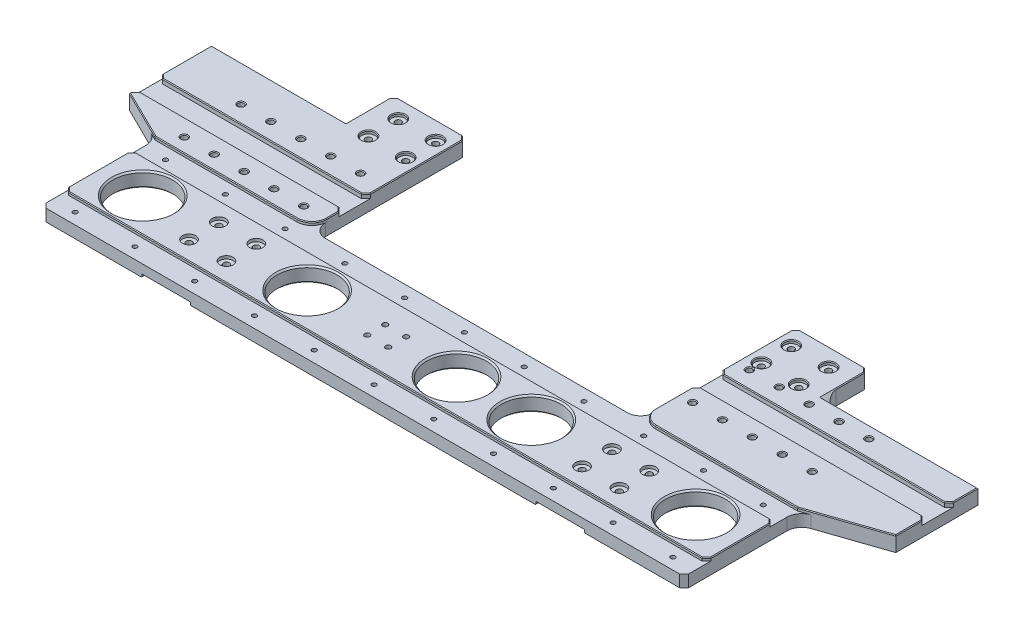
from build123d import *

# Parameters (mm, degrees)
SKETCH1_R           = 2
SKETCH1_R_2         = 20
BOSS_EXTRUDE1_DEPTH = 3
SKETCH2_W           = 11.375
SKETCH2_H           = 179.75
BOSS_EXTRUDE2_DEPTH = 2
SKETCH6_W           = 56
SKETCH6_H           = 76
BOSS_EXTRUDE5_DEPTH = 8
SKETCH3_W           = 430
SKETCH3_H           = 45.5
SKETCH3_R           = 20
SKETCH3_R_2         = 4.45
SKETCH3_W_2         = 49
SKETCH3_H_2         = 103.75
SKETCH3_R_3         = 2
BOSS_EXTRUDE3_DEPTH = 2
SKETCH4_R           = 2
SKETCH4_R_2         = 20
SKETCH4_W           = 10.75
SKETCH4_H           = 179.75
BOSS_EXTRUDE4_DEPTH = 2
FILLET1_R           = 10
FILLET2_R           = 9
SKETCH9_R           = 1.5
CUT_EXTRUDE2_DEPTH  = 9
BOSS_EXTRUDE6_DEPTH = 10
SKETCH11_R          = 2
CUT_EXTRUDE3_DEPTH  = 11
SKETCH13_R          = 20
CUT_EXTRUDE5_DEPTH  = 11
CHAMFER2_SIZE       = 1
SKETCH12_W          = 139
SKETCH12_H          = 15
SKETCH12_W_2        = 154
CUT_EXTRUDE4_DEPTH  = 3
CHAMFER1_SIZE       = 3
CHAMFER3_SIZE       = 0.5
FILLET3_R           = 10
SKETCH14_R          = 1.75
CUT_EXTRUDE6_DEPTH  = 11


with BuildPart() as part:
    # Sketch1 → Boss-Extrude1 (new body, symmetric)
    with BuildSketch(Plane(origin=(0, 0, 0), x_dir=(1, 0, 0), z_dir=(0, 1, 0))):
        Polygon((-110, 76), (110, 76), (110, 179.75), (159, 179.75), (159, 0), (-159, 0), (-159, 179.75), (-110, 179.75), align=None)
        with Locations((-119, 167.75)):
            Circle(SKETCH1_R, mode=Mode.SUBTRACT)
        with Locations((-144, 167.75)):
            Circle(SKETCH1_R, mode=Mode.SUBTRACT)
        with Locations((-144, 147.75)):
            Circle(SKETCH1_R, mode=Mode.SUBTRACT)
        with Locations((-119, 147.75)):
            Circle(SKETCH1_R, mode=Mode.SUBTRACT)
        with Locations((-119, 27.75)):
            Circle(SKETCH1_R, mode=Mode.SUBTRACT)
        with Locations((-119, 47.75)):
            Circle(SKETCH1_R, mode=Mode.SUBTRACT)
        with Locations((-144, 47.75)):
            Circle(SKETCH1_R, mode=Mode.SUBTRACT)
        with Locations((-144, 27.75)):
            Circle(SKETCH1_R, mode=Mode.SUBTRACT)
        with Locations((144, 167.75)):
            Circle(SKETCH1_R, mode=Mode.SUBTRACT)
        with Locations((119, 167.75)):
            Circle(SKETCH1_R, mode=Mode.SUBTRACT)
        with Locations((144, 147.75)):
            Circle(SKETCH1_R, mode=Mode.SUBTRACT)
        with Locations((119, 147.75)):
            Circle(SKETCH1_R, mode=Mode.SUBTRACT)
        with Locations((144, 27.75)):
            Circle(SKETCH1_R, mode=Mode.SUBTRACT)
        with Locations((144, 47.75)):
            Circle(SKETCH1_R, mode=Mode.SUBTRACT)
        with Locations((119, 47.75)):
            Circle(SKETCH1_R, mode=Mode.SUBTRACT)
        with Locations((119, 27.75)):
            Circle(SKETCH1_R, mode=Mode.SUBTRACT)
        with Locations((-75, 37.75)):
            Circle(SKETCH1_R_2, mode=Mode.SUBTRACT)
        with Locations((75, 37.75)):
            Circle(SKETCH1_R_2, mode=Mode.SUBTRACT)
        with Locations((25, 37.75)):
            Circle(SKETCH1_R_2, mode=Mode.SUBTRACT)
        with Locations((-125, 123.55)):
            Circle(SKETCH1_R, mode=Mode.SUBTRACT)
        with Locations((-125, 85.55)):
            Circle(SKETCH1_R, mode=Mode.SUBTRACT)
        with Locations((119, 139.75)):
            Circle(SKETCH1_R, mode=Mode.SUBTRACT)
        with Locations((119, 101.75)):
            Circle(SKETCH1_R, mode=Mode.SUBTRACT)
    extrude(amount=BOSS_EXTRUDE1_DEPTH, both=True)

    # Sketch2 → Boss-Extrude2 (add)
    with BuildSketch(Plane(origin=(0, -3, 0), x_dir=(1, 0, 0), z_dir=(0, 1, 0))):
        with Locations((-153.3125, 89.875)):
            Rectangle(SKETCH2_W, SKETCH2_H)
    extrude(amount=-BOSS_EXTRUDE2_DEPTH)

    # Sketch6 → Boss-Extrude5 (add)
    with BuildSketch(Plane(origin=(0, 3, 0), x_dir=(1, 0, 0), z_dir=(0, 1, 0))):
        with Locations((187, 38)):
            Rectangle(SKETCH6_W, SKETCH6_H)
        with Locations((-187, 38)):
            Rectangle(SKETCH6_W, SKETCH6_H)
    extrude(amount=-BOSS_EXTRUDE5_DEPTH)

    # Sketch3 → Boss-Extrude3 (add)
    with BuildSketch(Plane(origin=(0, 3, 0), x_dir=(1, 0, 0), z_dir=(0, 1, 0))):
        with Locations((0, 37.75)):
            Rectangle(SKETCH3_W, SKETCH3_H)
        with Locations((-75, 37.75)):
            Circle(SKETCH3_R, mode=Mode.SUBTRACT)
        with Locations((25, 37.75)):
            Circle(SKETCH3_R, mode=Mode.SUBTRACT)
        with Locations((75, 37.75)):
            Circle(SKETCH3_R, mode=Mode.SUBTRACT)
        with Locations((-144, 47.75)):
            Circle(SKETCH3_R_2, mode=Mode.SUBTRACT)
        with Locations((-119, 47.75)):
            Circle(SKETCH3_R_2, mode=Mode.SUBTRACT)
        with Locations((-144, 27.75)):
            Circle(SKETCH3_R_2, mode=Mode.SUBTRACT)
        with Locations((-119, 27.75)):
            Circle(SKETCH3_R_2, mode=Mode.SUBTRACT)
        with Locations((119, 47.75)):
            Circle(SKETCH3_R_2, mode=Mode.SUBTRACT)
        with Locations((119, 27.75)):
            Circle(SKETCH3_R_2, mode=Mode.SUBTRACT)
        with Locations((144, 27.75)):
            Circle(SKETCH3_R_2, mode=Mode.SUBTRACT)
        with Locations((144, 47.75)):
            Circle(SKETCH3_R_2, mode=Mode.SUBTRACT)
        with Locations((-134.5, 127.875)):
            Rectangle(SKETCH3_W_2, SKETCH3_H_2)
        with Locations((-144, 167.75)):
            Circle(SKETCH3_R_2, mode=Mode.SUBTRACT)
        with Locations((-119, 167.75)):
            Circle(SKETCH3_R_2, mode=Mode.SUBTRACT)
        with Locations((-144, 147.75)):
            Circle(SKETCH3_R_2, mode=Mode.SUBTRACT)
        with Locations((-125, 123.55)):
            Circle(SKETCH3_R_3, mode=Mode.SUBTRACT)
        with Locations((-119, 147.75)):
            Circle(SKETCH3_R_2, mode=Mode.SUBTRACT)
        with Locations((-125, 85.55)):
            Circle(SKETCH3_R_3, mode=Mode.SUBTRACT)
        with Locations((134.5, 127.875)):
            Rectangle(SKETCH3_W_2, SKETCH3_H_2)
        with Locations((119, 167.75)):
            Circle(SKETCH3_R_2, mode=Mode.SUBTRACT)
        with Locations((119, 139.75)):
            Circle(SKETCH3_R_3, mode=Mode.SUBTRACT)
        with Locations((119, 147.75)):
            Circle(SKETCH3_R_2, mode=Mode.SUBTRACT)
        with Locations((119, 101.75)):
            Circle(SKETCH3_R_3, mode=Mode.SUBTRACT)
        with Locations((144, 147.75)):
            Circle(SKETCH3_R_2, mode=Mode.SUBTRACT)
        with Locations((144, 167.75)):
            Circle(SKETCH3_R_2, mode=Mode.SUBTRACT)
    extrude(amount=BOSS_EXTRUDE3_DEPTH)

    # Sketch4 → Boss-Extrude4 (add)
    with BuildSketch(Plane.XZ.offset(3)):
        Polygon((110, -179.75), (110, -76), (-110, -76), (-110, -179.75), (-115.375, -179.75), (-115.375, 0), (116, 0), (116, -179.75), align=None)
        with Locations((-100, -68)):
            Circle(SKETCH4_R, mode=Mode.SUBTRACT)
        with Locations((-60, -68)):
            Circle(SKETCH4_R, mode=Mode.SUBTRACT)
        with Locations((-20, -68)):
            Circle(SKETCH4_R, mode=Mode.SUBTRACT)
        with Locations((20, -68)):
            Circle(SKETCH4_R, mode=Mode.SUBTRACT)
        with Locations((60, -68)):
            Circle(SKETCH4_R, mode=Mode.SUBTRACT)
        with Locations((100, -68)):
            Circle(SKETCH4_R, mode=Mode.SUBTRACT)
        with Locations((100, -7.5)):
            Circle(SKETCH4_R, mode=Mode.SUBTRACT)
        with Locations((60, -7.5)):
            Circle(SKETCH4_R, mode=Mode.SUBTRACT)
        with Locations((20, -7.5)):
            Circle(SKETCH4_R, mode=Mode.SUBTRACT)
        with Locations((-20, -7.5)):
            Circle(SKETCH4_R, mode=Mode.SUBTRACT)
        with Locations((-60, -7.5)):
            Circle(SKETCH4_R, mode=Mode.SUBTRACT)
        with Locations((-100, -7.5)):
            Circle(SKETCH4_R, mode=Mode.SUBTRACT)
        with Locations((-75, -37.75)):
            Circle(SKETCH4_R_2, mode=Mode.SUBTRACT)
        with Locations((25, -37.75)):
            Circle(SKETCH4_R_2, mode=Mode.SUBTRACT)
        with Locations((75, -37.75)):
            Circle(SKETCH4_R_2, mode=Mode.SUBTRACT)
        with Locations((153.625, -89.875)):
            Rectangle(SKETCH4_W, SKETCH4_H)
    extrude(amount=BOSS_EXTRUDE4_DEPTH)

    # Fillet1
    fillet1_edges = [part.edges().sort_by_distance(p)[0] for p in [
        (-110, 4, -76),
        (110, 4, -76),
    ]]
    fillet(fillet1_edges, radius=FILLET1_R)

    # Fillet2
    fillet2_edges = [part.edges().sort_by_distance(p)[0] for p in [
        (110, -1, -76),
        (-110, -1, -76),
    ]]
    fillet(fillet2_edges, radius=FILLET2_R)

    # Sketch9 → Cut-Extrude2 (cut, through all)
    with BuildSketch(Plane(origin=(0, 3, 0), x_dir=(1, 0, 0), z_dir=(0, 1, 0))):
        with Locations((-200, 68)):
            Circle(SKETCH9_R)
        with Locations((-200, 7.5)):
            Circle(SKETCH9_R)
        with Locations((-160, 7.5)):
            Circle(SKETCH9_R)
        with Locations((-160, 68)):
            Circle(SKETCH9_R)
        with Locations((-120, 7.5)):
            Circle(SKETCH9_R)
        with Locations((-120, 68)):
            Circle(SKETCH9_R)
        with Locations((-80, 7.5)):
            Circle(SKETCH9_R)
        with Locations((-80, 68)):
            Circle(SKETCH9_R)
        with Locations((-40, 7.5)):
            Circle(SKETCH9_R)
        with Locations((-40, 68)):
            Circle(SKETCH9_R)
        with Locations((0, 7.5)):
            Circle(SKETCH9_R)
        with Locations((0, 68)):
            Circle(SKETCH9_R)
        with Locations((40, 7.5)):
            Circle(SKETCH9_R)
        with Locations((40, 68)):
            Circle(SKETCH9_R)
        with Locations((80, 7.5)):
            Circle(SKETCH9_R)
        with Locations((80, 68)):
            Circle(SKETCH9_R)
        with Locations((120, 7.5)):
            Circle(SKETCH9_R)
        with Locations((120, 68)):
            Circle(SKETCH9_R)
        with Locations((160, 7.5)):
            Circle(SKETCH9_R)
        with Locations((160, 68)):
            Circle(SKETCH9_R)
        with Locations((200, 7.5)):
            Circle(SKETCH9_R)
        with Locations((200, 68)):
            Circle(SKETCH9_R)
    extrude(amount=-CUT_EXTRUDE2_DEPTH, mode=Mode.SUBTRACT)

    # Sketch10 → Boss-Extrude6 (add)
    with BuildSketch(Plane(origin=(0, 5, 0), x_dir=(1, 0, 0), z_dir=(0, 1, 0))):
        Polygon((159, 147.75), (264, 147.75), (264, 92.75), (215, 76), (159, 76), align=None)
        Polygon((-159, 147.75), (-249, 147.75), (-249, 92.75), (-215, 76), (-159, 76), align=None)
    extrude(amount=-BOSS_EXTRUDE6_DEPTH)

    # Sketch11 → Cut-Extrude3 (cut, through all)
    with BuildSketch(Plane(origin=(0, 5, 0), x_dir=(1, 0, 0), z_dir=(0, 1, 0))):
        with Locations((119, 101.75)):
            Circle(SKETCH11_R)
        with Locations((119, 139.75)):
            Circle(SKETCH11_R)
        with Locations((139, 139.75)):
            Circle(SKETCH11_R)
        with Locations((139, 101.75)):
            Circle(SKETCH11_R)
        with Locations((159, 139.75)):
            Circle(SKETCH11_R)
        with Locations((159, 101.75)):
            Circle(SKETCH11_R)
        with Locations((179, 139.75)):
            Circle(SKETCH11_R)
        with Locations((179, 101.75)):
            Circle(SKETCH11_R)
        with Locations((199, 139.75)):
            Circle(SKETCH11_R)
        with Locations((199, 101.75)):
            Circle(SKETCH11_R)
        with Locations((-125, 85.55)):
            Circle(SKETCH11_R)
        with Locations((-125, 123.55)):
            Circle(SKETCH11_R)
        with Locations((-145, 123.55)):
            Circle(SKETCH11_R)
        with Locations((-145, 85.55)):
            Circle(SKETCH11_R)
        with Locations((-165, 123.55)):
            Circle(SKETCH11_R)
        with Locations((-165, 85.55)):
            Circle(SKETCH11_R)
        with Locations((-185, 123.55)):
            Circle(SKETCH11_R)
        with Locations((-185, 85.55)):
            Circle(SKETCH11_R)
        with Locations((-205, 123.55)):
            Circle(SKETCH11_R)
        with Locations((-205, 85.55)):
            Circle(SKETCH11_R)
    extrude(amount=-CUT_EXTRUDE3_DEPTH, mode=Mode.SUBTRACT)

    # Sketch13 → Cut-Extrude5 (cut, through all)
    with BuildSketch(Plane(origin=(0, 5, 0), x_dir=(1, 0, 0), z_dir=(0, 1, 0))):
        with Locations((185, 37.75)):
            Circle(SKETCH13_R)
        with Locations((-185, 37.75)):
            Circle(SKETCH13_R)
    extrude(amount=-CUT_EXTRUDE5_DEPTH, mode=Mode.SUBTRACT)

    # Chamfer2
    chamfer2_edges = [part.edges().sort_by_distance(p)[0] for p in [
        (-95, 5, -37.75),
        (5, 5, -37.75),
        (55, 5, -37.75),
        (-95, -5, -37.75),
        (5, -5, -37.75),
        (55, -5, -37.75),
        (165, -5, -37.75),
        (165, 5, -37.75),
        (-205, -5, -37.75),
        (-205, 5, -37.75),
    ]]
    chamfer(chamfer2_edges, length=CHAMFER2_SIZE)

    # Sketch12 → Cut-Extrude4 (cut)
    with BuildSketch(Plane(origin=(0, 5, 0), x_dir=(1, 0, 0), z_dir=(0, 1, 0))):
        with Locations((-179.5, 104.55)):
            Rectangle(SKETCH12_W, SKETCH12_H)
        with Locations((187, 120.75)):
            Rectangle(SKETCH12_W_2, SKETCH12_H)
    extrude(amount=-CUT_EXTRUDE4_DEPTH, mode=Mode.SUBTRACT)

    # Chamfer1
    chamfer1_edges = [part.edges().sort_by_distance(p)[0] for p in [
        (215, -1, 0),
        (-215, -1, 0),
        (215, 4, -15),
        (215, 4, -60.5),
        (-215, 4, -60.5),
        (-215, 4, -15),
        (110, 0, -179.75),
        (159, 0, -179.75),
        (-159, 0, -179.75),
        (-110, 0, -179.75),
        (-110, 3.5, -112.05),
        (-110, 3.5, -97.05),
        (-249, 3.5, -97.05),
        (-249, 3.5, -112.05),
        (110, 3.5, -113.25),
        (110, 3.5, -128.25),
        (264, 3.5, -128.25),
        (264, 3.5, -113.25),
    ]]
    chamfer(chamfer1_edges, length=CHAMFER1_SIZE)

    # Chamfer3
    chamfer3_edges = [part.edges().sort_by_distance(p)[0] for p in [
        (-167.5, 5, -76),
        (-148.45, 5, -167.75),
        (-123.45, 5, -167.75),
        (-148.45, 5, -147.75),
        (-127, 5, -123.55),
        (-123.45, 5, -147.75),
        (-127, 5, -85.55),
        (114.55, 5, -167.75),
        (117, 5, -139.75),
        (114.55, 5, -147.75),
        (117, 5, -101.75),
        (139.55, 5, -147.75),
        (139.55, 5, -167.75),
        (116, -5, -89.875),
        (-115.375, -5, -89.875),
        (148.25, -5, -89.875),
        (-110, 5, -90.025),
        (-112.928932188, 5, -78.928932188),
        (167.5, 5, -76),
        (112.928932188, 5, -78.928932188),
        (159, 5, -162.25),
        (239.5, 5, -84.375),
        (264, 5, -101.5),
        (211.5, 5, -147.75),
        (-204, 5, -147.75),
        (-249, 5, -131.4),
        (-232, 5, -84.375),
        (-147, 5, -85.55),
        (197, 5, -139.75),
        (-187, 5, -85.55),
        (-167, 5, -123.55),
        (-167, 5, -85.55),
        (-147, 5, -123.55),
        (157, 5, -101.75),
        (137, 5, -139.75),
        (137, 5, -101.75),
        (197, 5, -101.75),
        (177, 5, -139.75),
        (177, 5, -101.75),
        (157, 5, -139.75),
        (-207, 5, -123.55),
        (-207, 5, -85.55),
        (-187, 5, -123.55),
        (264, 5, -139.5),
        (187, 5, -113.25),
        (110, 5, -98.125),
        (111.5, 5, -111.75),
        (262.5, 5, -111.75),
        (187, 5, -128.25),
        (134.5, 5, -179.75),
        (110, 5, -154),
        (111.5, 5, -178.25),
        (157.5, 5, -178.25),
        (111.5, 5, -129.75),
        (262.5, 5, -129.75),
        (-179.5, 5, -97.05),
        (-249, 5, -93.4),
        (-111.5, 5, -95.55),
        (-247.5, 5, -95.55),
        (-179.5, 5, -112.05),
        (-110, 5, -145.9),
        (-134.5, 5, -179.75),
        (-159, 5, -162.25),
        (-157.5, 5, -178.25),
        (-111.5, 5, -178.25),
        (-111.5, 5, -113.55),
        (-247.5, 5, -113.55),
        (0, 5, -15),
        (-215, 5, -37.75),
        (215, 5, -37.75),
        (0, 5, -60.5),
        (-213.5, 5, -59),
        (213.5, 5, -59),
        (213.5, 5, -16.5),
        (-213.5, 5, -16.5),
        (-147.625, -5, -89.875),
    ]]
    chamfer(chamfer3_edges, length=CHAMFER3_SIZE)

    # Fillet3
    fillet3_edges = [part.edges().sort_by_distance(p)[0] for p in [
        (215, -1, -76),
        (-215, -1, -76),
        (159, -0.25, -147.75),
        (-159, -0.25, -147.75),
    ]]
    fillet(fillet3_edges, radius=FILLET3_R)

    # Sketch14 → Cut-Extrude6 (cut, through all)
    with BuildSketch(Plane.XZ.offset(5)):
        with Locations((-15, -32)):
            Circle(SKETCH14_R)
        with Locations((-29, -32)):
            Circle(SKETCH14_R)
        with Locations((-29, -44)):
            Circle(SKETCH14_R)
        with Locations((-15, -44)):
            Circle(SKETCH14_R)
    extrude(amount=-CUT_EXTRUDE6_DEPTH, mode=Mode.SUBTRACT)


solid = part.part
